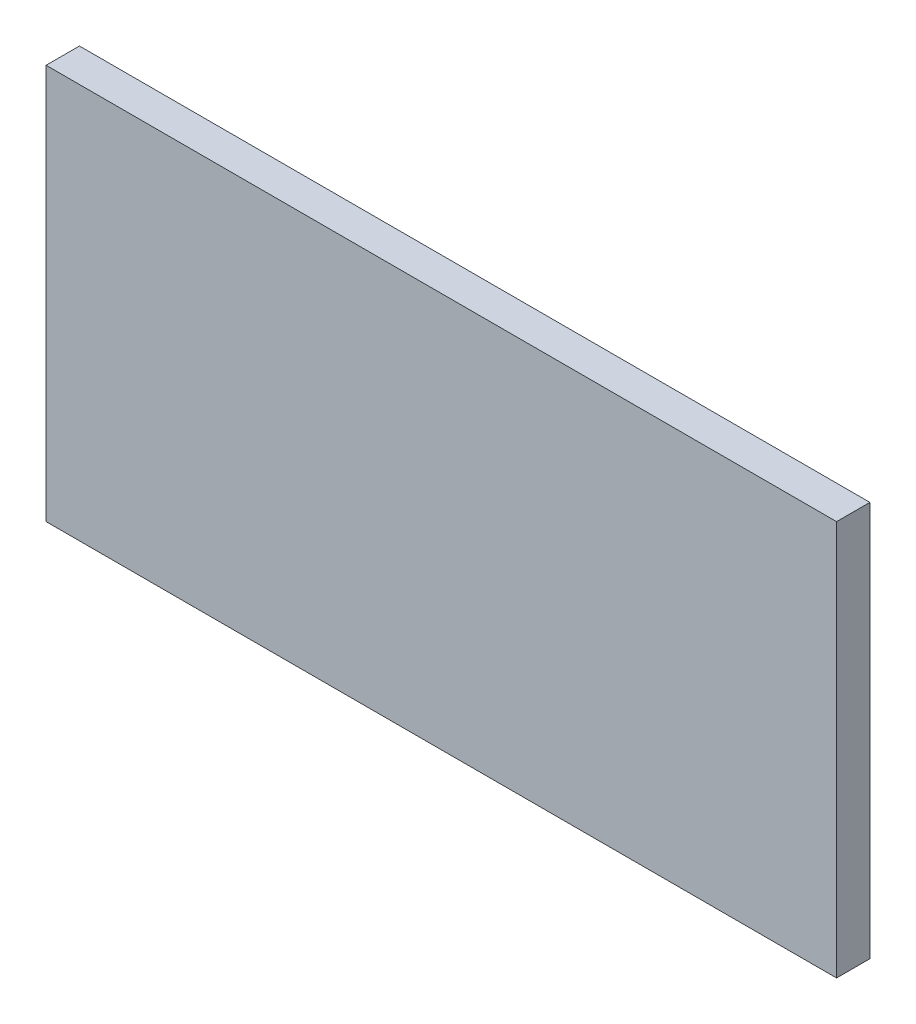
from build123d import *

# Parameters (mm, degrees)
SKETCH1_W           = 35.56
SKETCH1_H           = 17.78
BOSS_EXTRUDE1_DEPTH = 1.5


with BuildPart() as part:
    # Sketch1 → Boss-Extrude1 (new body)
    with BuildSketch(Plane.XY):
        Rectangle(SKETCH1_W, SKETCH1_H)
    extrude(amount=BOSS_EXTRUDE1_DEPTH)


solid = part.part
